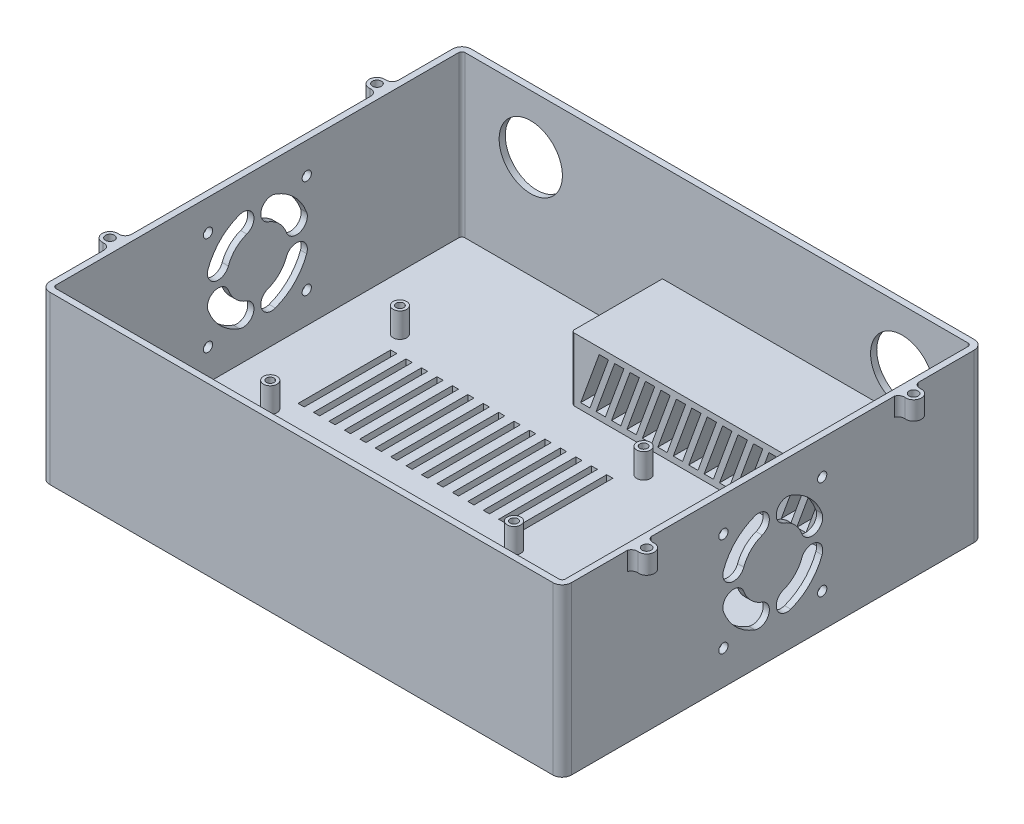
from build123d import *

# Parameters (mm, degrees)
EXTRUDE_4_DEPTH      = 52
EXTRUDE_5_DEPTH      = 2
EXTRUDE_6_DEPTH      = 20.5
SKETCH_14_R          = 10.25
CUT_EXTRUDE_2_DEPTH  = 2
CUT_EXTRUDE_4_DEPTH  = 35
CUT_EXTRUDE_5_DEPTH  = 0.05
SKETCH_25_R          = 10.15
CUT_EXTRUDE_6_DEPTH  = 2
SKETCH_26_R          = 2.2
SKETCH_26_R_2        = 1.25
EXTRUDE_13_DEPTH     = 8
SKETCH_30_W          = 2
SKETCH_30_H          = 30
CUT_EXTRUDE_8_DEPTH  = 8
SKETCH_31_R          = 1.5
CUT_EXTRUDE_11_DEPTH = 8
SKETCH_35_R          = 1.5
CUT_EXTRUDE_12_DEPTH = 8
SKETCH_37_R          = 1.45
EXTRUDE_14_DEPTH     = 6


with BuildPart() as part:
    # 草图2 → 凸台-拉伸4 (new body)
    with BuildSketch(Plane(origin=(0, 0, 0), x_dir=(1, 0, 0), z_dir=(0, 1, 0))):
        with BuildLine():
            Line((-81.5, -68.25), (81.5, -68.25))
            ThreePointArc((81.5, -68.25), (83.621320344, -67.371320344), (84.5, -65.25))
            Line((84.5, -65.25), (84.5, 65.25))
            ThreePointArc((84.5, 65.25), (83.621320344, 67.371320344), (81.5, 68.25))
            Line((81.5, 68.25), (-81.5, 68.25))
            ThreePointArc((-81.5, 68.25), (-83.621320344, 67.371320344), (-84.5, 65.25))
            Line((-84.5, 65.25), (-84.5, -65.25))
            ThreePointArc((-84.5, -65.25), (-83.621320344, -67.371320344), (-81.5, -68.25))
        make_face()
        with BuildLine():
            Line((-81.5, -66.25), (81.5, -66.25))
            ThreePointArc((81.5, -66.25), (82.207106781, -65.957106781), (82.5, -65.25))
            Line((82.5, -65.25), (82.5, 65.25))
            ThreePointArc((82.5, 65.25), (82.207106781, 65.957106781), (81.5, 66.25))
            Line((81.5, 66.25), (-81.5, 66.25))
            ThreePointArc((-81.5, 66.25), (-82.207106781, 65.957106781), (-82.5, 65.25))
            Line((-82.5, 65.25), (-82.5, -65.25))
            ThreePointArc((-82.5, -65.25), (-82.207106781, -65.957106781), (-81.5, -66.25))
        make_face(mode=Mode.SUBTRACT)
    extrude(amount=EXTRUDE_4_DEPTH)

    # 草图6 → 凸台-拉伸5 (add)
    with BuildSketch(Plane(origin=(0, 0, 0), x_dir=(-1, 0, 0), z_dir=(0, -1, 0))):
        with BuildLine():
            Line((81.5, -68.25), (-81.5, -68.25))
            ThreePointArc((-81.5, -68.25), (-83.621320344, -67.371320344), (-84.5, -65.25))
            Line((-84.5, -65.25), (-84.5, 65.25))
            ThreePointArc((-84.5, 65.25), (-83.621320344, 67.371320344), (-81.5, 68.25))
            Line((-81.5, 68.25), (81.5, 68.25))
            ThreePointArc((81.5, 68.25), (83.621320344, 67.371320344), (84.5, 65.25))
            Line((84.5, 65.25), (84.5, -65.25))
            ThreePointArc((84.5, -65.25), (83.621320344, -67.371320344), (81.5, -68.25))
        make_face()
    extrude(amount=EXTRUDE_5_DEPTH)

    # 草图7 → 凸台-拉伸6 (add)
    with BuildSketch(Plane(origin=(0, 0, 0), x_dir=(1, 0, 0), z_dir=(0, 1, 0))):
        with BuildLine():
            Line((-17.5, 66.25), (82.5, 66.25))
            Line((82.5, 66.25), (82.5, 36.75))
            Line((82.5, 36.75), (-16.5, 36.75))
            ThreePointArc((-16.5, 36.75), (-17.207106781, 37.042893219), (-17.5, 37.75))
            Line((-17.5, 37.75), (-17.5, 66.25))
        make_face()
    extrude(amount=EXTRUDE_6_DEPTH)

    # 草图14 → 切除-拉伸2 (cut)
    with BuildSketch(Plane(origin=(0, 0, -68.25), x_dir=(-1, 0, 0), z_dir=(0, 0, -1))):
        with Locations((-60.175, 33.275)):
            Circle(SKETCH_14_R)
        with Locations((60.175, 33.275)):
            Circle(SKETCH_14_R)
    extrude(amount=-CUT_EXTRUDE_2_DEPTH, mode=Mode.SUBTRACT)

    # 草图20 → 切除-拉伸4 (cut)
    with BuildSketch(Plane.XY.offset(-36.75)):
        Polygon((-14.5, 2), (-8.494491135, 18.5), (-5.494491135, 18.5), (-11.5, 2), align=None)
        Polygon((-9.5, 2), (-3.494491135, 18.5), (-0.494491135, 18.5), (-6.5, 2), align=None)
        Polygon((-4.5, 2), (1.505508865, 18.5), (4.505508865, 18.5), (-1.5, 2), align=None)
        Polygon((0.5, 2), (6.505508865, 18.5), (9.505508865, 18.5), (3.5, 2), align=None)
        Polygon((5.5, 2), (11.505508865, 18.5), (14.505508865, 18.5), (8.5, 2), align=None)
        Polygon((10.5, 2), (16.505508865, 18.5), (19.505508865, 18.5), (13.5, 2), align=None)
        Polygon((15.5, 2), (21.505508865, 18.5), (24.505508865, 18.5), (18.5, 2), align=None)
        Polygon((20.5, 2), (26.505508865, 18.5), (29.505508865, 18.5), (23.5, 2), align=None)
        Polygon((25.5, 2), (31.505508865, 18.5), (34.505508865, 18.5), (28.5, 2), align=None)
        Polygon((30.5, 2), (36.505508865, 18.5), (39.505508865, 18.5), (33.5, 2), align=None)
        Polygon((35.5, 2), (41.505508865, 18.5), (44.505508865, 18.5), (38.5, 2), align=None)
        Polygon((40.5, 2), (46.505508865, 18.5), (49.505508865, 18.5), (43.5, 2), align=None)
        Polygon((45.5, 2), (51.505508865, 18.5), (54.505508865, 18.5), (48.5, 2), align=None)
        Polygon((50.5, 2), (56.505508865, 18.5), (59.505508865, 18.5), (53.5, 2), align=None)
        Polygon((55.5, 2), (61.505508865, 18.5), (64.505508865, 18.5), (58.5, 2), align=None)
        Polygon((60.5, 2), (66.505508865, 18.5), (69.505508865, 18.5), (63.5, 2), align=None)
        Polygon((65.5, 2), (71.505508865, 18.5), (74.505508865, 18.5), (68.5, 2), align=None)
        Polygon((70.5, 2), (76.505508865, 18.5), (79.505508865, 18.5), (73.5, 2), align=None)
    extrude(amount=-CUT_EXTRUDE_4_DEPTH, mode=Mode.SUBTRACT)

    # 草图22 → 切除-拉伸5 (cut)
    with BuildSketch(Plane(origin=(0, 0, -68.25), x_dir=(-1, 0, 0), z_dir=(0, 0, -1))):
        with BuildLine():
            Line((31.2634375, 13.66), (27.5371875, 13.66))
            add(Edge.make_bspline(
                [(27.5371875, 13.66), (27.496962608, 13.835011517), (27.421006184, 14.165484724), (27.262554429, 14.622537656), (27.058671902, 15.00379895), (26.823863835, 15.319857525), (26.545806469, 15.562810535), (26.229939815, 15.740648132), (25.870213139, 15.840923537), (25.618524328, 15.853499856), (25.4884375, 15.86)],
                knots=[0, 0, 0, 0, 0.000538581, 0.001016999, 0.001446081, 0.001831096, 0.002191657, 0.002545569, 0.00291009, 0.003300046, 0.003300046, 0.003300046, 0.003300046], degree=3))
            add(Edge.make_bspline(
                [(25.4884375, 15.86), (25.383866285, 15.856190077), (25.179668881, 15.848750397), (24.883235573, 15.785994448), (24.60857001, 15.678031521), (24.354211787, 15.527249422), (24.118898633, 15.33649407), (23.903499541, 15.102777221), (23.71194781, 14.825103728), (23.539810148, 14.506718364), (23.390562451, 14.146389178), (23.254241995, 13.746594751), (23.149227013, 13.302550808), (23.053184478, 12.819324784), (22.98871941, 12.292893918), (22.936179888, 11.725567756), (22.90555333, 11.116582917), (22.901890431, 10.696907844), (22.9, 10.4803125)],
                knots=[0, 0, 0, 0, 0.000313492, 0.000612159, 0.000903881, 0.001195116, 0.001495755, 0.001809548, 0.002145229, 0.002505166, 0.002893345, 0.003314028, 0.003770906, 0.004261024, 0.004791436, 0.005360962, 0.005970185, 0.006619955, 0.006619955, 0.006619955, 0.006619955], degree=3))
            add(Edge.make_bspline(
                [(22.9, 10.4803125), (22.902185948, 10.247683479), (22.906419447, 9.797153737), (22.932913963, 9.145867531), (22.98011831, 8.541414907), (23.049105701, 7.98536753), (23.132497005, 7.475253762), (23.23947512, 7.014090437), (23.360861427, 6.599291438), (23.505464064, 6.232077204), (23.670046106, 5.907957491), (23.859150437, 5.629155807), (24.06729842, 5.390029002), (24.299174274, 5.194101438), (24.556540822, 5.046345225), (24.833014167, 4.937671858), (25.131153299, 4.870255117), (25.337974868, 4.863470082), (25.44375, 4.86)],
                knots=[0, 0, 0, 0, 0.000697889, 0.001351592, 0.001955077, 0.00251618, 0.003032137, 0.003504927, 0.00393559, 0.004327525, 0.004687282, 0.005023841, 0.005335576, 0.005635742, 0.005929945, 0.006221667, 0.006524421, 0.006841343, 0.006841343, 0.006841343, 0.006841343], degree=3))
            add(Edge.make_bspline(
                [(25.44375, 4.86), (25.528687053, 4.862564739), (25.693893769, 4.867553281), (25.934958076, 4.908673122), (26.158786664, 4.983166976), (26.372488067, 5.078095757), (26.567399238, 5.208347989), (26.753306745, 5.359117741), (26.917588837, 5.544827942), (27.069351835, 5.75568342), (27.206419006, 5.992877228), (27.326644736, 6.256999419), (27.433017069, 6.546694947), (27.524433558, 6.862838893), (27.604792756, 7.204396985), (27.66435339, 7.573331342), (27.713994403, 7.967632142), (27.731175596, 8.24007241), (27.74, 8.38)],
                knots=[0, 0, 0, 0, 0.000254746, 0.000495494, 0.000730303, 0.000961026, 0.001194624, 0.001431413, 0.001677212, 0.001935757, 0.002209918, 0.00249754, 0.002805326, 0.003134914, 0.00348429, 0.00385727, 0.004255501, 0.004676016, 0.004676016, 0.004676016, 0.004676016], degree=3))
            Line((27.74, 8.38), (25.4196875, 8.3903125))
            Line((25.4196875, 8.3903125), (25.4196875, 11.02))
            Line((25.4196875, 11.02), (31.48, 11.02))
            Line((31.48, 11.02), (31.48, 2))
            Line((31.48, 2), (29.795625, 2))
            Line((29.795625, 2), (29.4003125, 3.670625))
            add(Edge.make_bspline(
                [(29.4003125, 3.670625), (29.26487517, 3.518492854), (28.999731901, 3.220666439), (28.555005306, 2.83586519), (28.093941014, 2.505930703), (27.608025255, 2.236868526), (27.093045652, 2.034179505), (26.550836946, 1.884381642), (25.975834409, 1.798764676), (25.582672477, 1.786343699), (25.381875, 1.78)],
                knots=[0, 0, 0, 0, 0.000610493, 0.001195151, 0.001759791, 0.002309028, 0.002856713, 0.003416276, 0.003993336, 0.004595694, 0.004595694, 0.004595694, 0.004595694], degree=3))
            add(Edge.make_bspline(
                [(25.381875, 1.78), (25.164840843, 1.787283395), (24.738221211, 1.801600216), (24.114128669, 1.914212708), (23.522398963, 2.099790924), (22.962644358, 2.362942266), (22.430094063, 2.692712099), (21.932067871, 3.104106069), (21.467528288, 3.589206515), (21.035914601, 4.142139484), (20.647235175, 4.75528871), (20.30447631, 5.418133886), (20.019731586, 6.130309131), (19.787971612, 6.888743117), (19.600505874, 7.692168305), (19.472044452, 8.542684359), (19.396619086, 9.439667584), (19.385629981, 10.052768682), (19.38, 10.366875)],
                knots=[0, 0, 0, 0, 0.000650787, 0.001279239, 0.001895664, 0.002506205, 0.003130014, 0.00376998, 0.004438528, 0.005141301, 0.005870805, 0.006613376, 0.007376819, 0.00816837, 0.008990536, 0.009849588, 0.010746532, 0.011688808, 0.011688808, 0.011688808, 0.011688808], degree=3))
            add(Edge.make_bspline(
                [(19.38, 10.366875), (19.385431688, 10.688999699), (19.39602221, 11.317067631), (19.473873157, 12.233953087), (19.611842425, 13.098564382), (19.799631554, 13.91121919), (20.038376599, 14.673186461), (20.339553818, 15.379559664), (20.689713444, 16.037406359), (21.095225972, 16.637787707), (21.543871715, 17.179698854), (22.038083603, 17.651669199), (22.575217085, 18.048726811), (23.14804686, 18.379168578), (23.763411254, 18.631927924), (24.417277608, 18.80815386), (25.109678774, 18.923545478), (25.58535465, 18.934430379), (25.82875, 18.94)],
                knots=[0, 0, 0, 0, 0.000966329, 0.001884116, 0.002757816, 0.003590805, 0.004384413, 0.005149935, 0.005891224, 0.006616765, 0.007319647, 0.00799802, 0.008661467, 0.009318929, 0.009977082, 0.010650911, 0.011347155, 0.012076715, 0.012076715, 0.012076715, 0.012076715], degree=3))
            add(Edge.make_bspline(
                [(25.82875, 18.94), (26.012270844, 18.936402955), (26.372507275, 18.929342248), (26.899750301, 18.863153512), (27.40081752, 18.751980613), (27.879371109, 18.602785024), (28.32852279, 18.400547582), (28.757338009, 18.163529703), (29.155620397, 17.876381138), (29.527076584, 17.548043066), (29.872786478, 17.185205851), (30.177333078, 16.780171819), (30.450747433, 16.344800195), (30.689832215, 15.875021945), (30.886538744, 15.368353195), (31.052957042, 14.830075331), (31.180115255, 14.257304211), (31.23524192, 13.86212296), (31.2634375, 13.66)],
                knots=[0, 0, 0, 0, 0.000550387, 0.001080364, 0.001590795, 0.002088699, 0.002581174, 0.003065971, 0.003556282, 0.004050721, 0.004551653, 0.005056977, 0.005568195, 0.006092422, 0.006635645, 0.007196706, 0.007781333, 0.008393411, 0.008393411, 0.008393411, 0.008393411], degree=3))
        make_face()
        Polygon((38.375625, 18.5), (41.69625, 18.5), (47.32, 2), (43.7175, 2), (42.5315625, 5.74), (37.3890625, 5.74), (36.2615625, 2), (32.8, 2), align=None)
        Polygon((40.0084375, 14.4059375), (38.306875, 8.6), (41.675625, 8.6), align=None, mode=Mode.SUBTRACT)
        Polygon((52.675625, 18.5), (55.99625, 18.5), (61.62, 2), (58.0175, 2), (56.8315625, 5.74), (51.6890625, 5.74), (50.5615625, 2), (47.1, 2), align=None)
        Polygon((54.3084375, 14.4059375), (52.606875, 8.6), (55.975625, 8.6), align=None, mode=Mode.SUBTRACT)
        with BuildLine():
            Line((74.38, 13.66), (71.08, 13.66))
            Line((71.08, 13.66), (71.08, 13.8490625))
            add(Edge.make_bspline(
                [(71.08, 13.8490625), (71.072365078, 13.990895658), (71.057539839, 14.266302569), (70.93320551, 14.658978566), (70.723557061, 15.00707895), (70.439648089, 15.309515818), (70.092877094, 15.557034989), (69.690543734, 15.734362389), (69.242062357, 15.843051067), (68.926473048, 15.854219338), (68.763125, 15.86)],
                knots=[0, 0, 0, 0, 0.00042482, 0.000824901, 0.001221065, 0.001634538, 0.002060912, 0.002490215, 0.002946276, 0.00343561, 0.00343561, 0.00343561, 0.00343561], degree=3))
            add(Edge.make_bspline(
                [(68.763125, 15.86), (68.598784198, 15.854818957), (68.283039405, 15.84486472), (67.833666623, 15.748172435), (67.434755073, 15.584581067), (67.088835237, 15.36358858), (66.812103506, 15.086313106), (66.60326087, 14.770457159), (66.483671432, 14.408344563), (66.468034668, 14.154703749), (66.46, 14.024375)],
                knots=[0, 0, 0, 0, 0.000492535, 0.000946298, 0.001370171, 0.001780157, 0.002169066, 0.002537119, 0.00290671, 0.003297332, 0.003297332, 0.003297332, 0.003297332], degree=3))
            add(Edge.make_bspline(
                [(66.46, 14.024375), (66.466097065, 13.892748487), (66.477766622, 13.640820223), (66.599256899, 13.288941232), (66.798730643, 12.990484647), (67.028606275, 12.784202815), (67.266547487, 12.644848315), (67.501503557, 12.541034494), (67.788538795, 12.434546149), (68.128749781, 12.330090229), (68.520407515, 12.22277498), (68.965320078, 12.12293368), (69.460459477, 12.013394142), (69.81016379, 11.950306808), (69.99375, 11.9171875)],
                knots=[0, 0, 0, 0, 0.000393695, 0.000753518, 0.001100552, 0.001460818, 0.001668921, 0.001925816, 0.002230379, 0.002586985, 0.002993091, 0.003448362, 0.003954702, 0.004514286, 0.004514286, 0.004514286, 0.004514286], degree=3))
            add(Edge.make_bspline(
                [(69.99375, 11.9171875), (70.221092258, 11.865253275), (70.65851235, 11.765328723), (71.2816918, 11.590517161), (71.846324771, 11.400100229), (72.357108228, 11.206000471), (72.805795887, 10.985324838), (73.203094506, 10.763463844), (73.540470904, 10.520692202), (73.825231063, 10.263026809), (74.06393336, 9.981118765), (74.266858721, 9.673545736), (74.439772949, 9.337103124), (74.581825675, 8.971067713), (74.68499545, 8.573598766), (74.766415111, 8.149093128), (74.808691734, 7.694493054), (74.816162546, 7.382051217), (74.82, 7.2215625)],
                knots=[0, 0, 0, 0, 0.000699538, 0.001345952, 0.00194056, 0.002486982, 0.002983567, 0.003439357, 0.003850551, 0.004227691, 0.004588612, 0.004955668, 0.005330797, 0.005721479, 0.006130903, 0.006561044, 0.007016989, 0.007498546, 0.007498546, 0.007498546, 0.007498546], degree=3))
            add(Edge.make_bspline(
                [(74.82, 7.2215625), (74.814367205, 7.015088798), (74.803375476, 6.612179953), (74.727990838, 6.024570554), (74.598469196, 5.470784073), (74.410452027, 4.953437488), (74.177632208, 4.46666118), (73.884558212, 4.017746706), (73.544531137, 3.599324251), (73.149593007, 3.221738284), (72.712959147, 2.880395582), (72.232753059, 2.583259995), (71.709723965, 2.3355355), (71.147003143, 2.134550551), (70.546530351, 1.970974021), (69.904447677, 1.859235018), (69.222785738, 1.794828793), (68.755244099, 1.785024688), (68.515625, 1.78)],
                knots=[0, 0, 0, 0, 0.000619361, 0.001208609, 0.001773908, 0.002321928, 0.002856942, 0.003388989, 0.003926406, 0.004470965, 0.005024498, 0.005586369, 0.006161419, 0.006757307, 0.007376868, 0.008026228, 0.00870998, 0.00942882, 0.00942882, 0.00942882, 0.00942882], degree=3))
            add(Edge.make_bspline(
                [(68.515625, 1.78), (68.295385118, 1.784058311), (67.864996089, 1.791988994), (67.237201904, 1.870275633), (66.644407282, 1.992190188), (66.085293518, 2.164477766), (65.561730834, 2.389031064), (65.069704667, 2.65979228), (64.617368798, 2.987843521), (64.197075003, 3.357576305), (63.820349168, 3.773643895), (63.486928964, 4.226607818), (63.204882363, 4.718889499), (62.966097376, 5.246747706), (62.778248026, 5.814169089), (62.634283086, 6.416596341), (62.536354001, 7.0559805), (62.512314202, 7.495076472), (62.5, 7.72)],
                knots=[0, 0, 0, 0, 0.000660438, 0.001290618, 0.001894679, 0.002474191, 0.003042461, 0.003601042, 0.00415529, 0.004715381, 0.005277504, 0.005835788, 0.006399455, 0.006976402, 0.00757101, 0.008189655, 0.008832835, 0.009508301, 0.009508301, 0.009508301, 0.009508301], degree=3))
            Line((62.5, 7.72), (65.8, 7.72))
            add(Edge.make_bspline(
                [(65.8, 7.72), (65.805032973, 7.615558248), (65.814920571, 7.410375751), (65.861011095, 7.110340962), (65.927416611, 6.825317956), (66.024177068, 6.557824163), (66.133237274, 6.302196261), (66.278495788, 6.06802242), (66.440187503, 5.84607549), (66.623757299, 5.640015228), (66.832049096, 5.459472201), (67.050585364, 5.295953284), (67.287644557, 5.160871928), (67.538206729, 5.051894714), (67.802652029, 4.96464472), (68.082268783, 4.90216864), (68.377357757, 4.869611996), (68.57857741, 4.863234378), (68.680625, 4.86)],
                knots=[0, 0, 0, 0, 0.000313492, 0.000615874, 0.000909353, 0.001189841, 0.001468364, 0.001741315, 0.002014267, 0.002291748, 0.002566941, 0.002839892, 0.003109358, 0.003383346, 0.003658368, 0.003943597, 0.004241214, 0.004547461, 0.004547461, 0.004547461, 0.004547461], degree=3))
            add(Edge.make_bspline(
                [(68.680625, 4.86), (68.888510783, 4.866940838), (69.285706028, 4.880202293), (69.847236499, 4.988092119), (70.340930963, 5.174695862), (70.694458126, 5.396505908), (70.938080025, 5.604355586), (71.092064043, 5.776913783), (71.224201091, 5.961478182), (71.336154067, 6.157100813), (71.417803689, 6.368565834), (71.476030326, 6.592361959), (71.516105676, 6.828253745), (71.5186886, 6.991080015), (71.52, 7.07375)],
                knots=[0, 0, 0, 0, 0.000623335, 0.001190971, 0.001706779, 0.002197957, 0.002434346, 0.00266558, 0.002889757, 0.00311446, 0.003339793, 0.003567422, 0.003807605, 0.004055319, 0.004055319, 0.004055319, 0.004055319], degree=3))
            add(Edge.make_bspline(
                [(71.52, 7.07375), (71.51722885, 7.134662568), (71.511675291, 7.256735164), (71.470579708, 7.436587609), (71.39480303, 7.607767039), (71.295123368, 7.773699379), (71.164818538, 7.932374813), (71.011104524, 8.087656174), (70.824558509, 8.232313982), (70.612149149, 8.372837851), (70.369566298, 8.5057978), (70.101729008, 8.636806879), (69.804446326, 8.76073065), (69.479118728, 8.875658796), (69.126305381, 8.986997456), (68.743725143, 9.088362931), (68.333755094, 9.188565552), (68.049473349, 9.24715463), (67.90375, 9.2771875)],
                knots=[0, 0, 0, 0, 0.000182706, 0.000366154, 0.000549408, 0.000742184, 0.000945113, 0.001163874, 0.001396332, 0.001651842, 0.001927293, 0.002225544, 0.002546026, 0.002892873, 0.003260348, 0.0036556, 0.004079975, 0.004526294, 0.004526294, 0.004526294, 0.004526294], degree=3))
            add(Edge.make_bspline(
                [(67.90375, 9.2771875), (67.832638433, 9.291760737), (67.699430472, 9.319059689), (67.513315481, 9.362184079), (67.352244514, 9.39473015), (67.254014033, 9.417905767), (67.209375, 9.4284375)],
                knots=[0, 0, 0, 0, 0.00021776, 0.000407913, 0.000573092, 0.000710678, 0.000710678, 0.000710678, 0.000710678], degree=3))
            add(Edge.make_bspline(
                [(67.209375, 9.4284375), (67.027848568, 9.470094214), (66.675234903, 9.551012052), (66.169512757, 9.699985849), (65.700639806, 9.86203426), (65.273884264, 10.049677233), (64.883338729, 10.248127232), (64.529981833, 10.463060269), (64.220593676, 10.702413156), (63.943545328, 10.954825356), (63.704437138, 11.231657323), (63.501543089, 11.534631443), (63.324101968, 11.857653845), (63.183254116, 12.208930214), (63.07409334, 12.584437603), (62.994421949, 12.984542195), (62.951197477, 13.409259496), (62.943794828, 13.700013154), (62.94, 13.8490625)],
                knots=[0, 0, 0, 0, 0.000558612, 0.0010851, 0.001580863, 0.002045778, 0.002482395, 0.002894508, 0.003284342, 0.003654093, 0.00401725, 0.004378596, 0.004746216, 0.005120919, 0.00551142, 0.005917932, 0.0063431, 0.006790305, 0.006790305, 0.006790305, 0.006790305], degree=3))
            add(Edge.make_bspline(
                [(62.94, 13.8490625), (62.944289507, 14.034961479), (62.952690594, 14.39904845), (63.02826329, 14.930355593), (63.141807623, 15.436298302), (63.313153955, 15.912101984), (63.526029347, 16.36273037), (63.789465872, 16.784511075), (64.100840906, 17.17865017), (64.458457142, 17.541010729), (64.852004966, 17.871001678), (65.280674643, 18.158174967), (65.740655107, 18.397748178), (66.227018381, 18.600479765), (66.74673817, 18.749644263), (67.294043798, 18.858363826), (67.870888837, 18.930806886), (68.26560722, 18.936889057), (68.4675, 18.94)],
                knots=[0, 0, 0, 0, 0.000557395, 0.001091669, 0.001606973, 0.002110364, 0.00260546, 0.003099552, 0.00359883, 0.004109296, 0.004624245, 0.00513717, 0.005653814, 0.006177905, 0.006715256, 0.007272778, 0.007850943, 0.008456294, 0.008456294, 0.008456294, 0.008456294], degree=3))
            add(Edge.make_bspline(
                [(68.4675, 18.94), (68.69685309, 18.936663177), (69.142798859, 18.930175179), (69.791628118, 18.862026982), (70.400642493, 18.759400738), (70.968312474, 18.606190768), (71.497717188, 18.414858477), (71.986583071, 18.178086772), (72.435314394, 17.897174725), (72.840704926, 17.573809381), (73.204856548, 17.212152571), (73.517841957, 16.809544346), (73.789961705, 16.375007788), (74.005244856, 15.900070483), (74.174991773, 15.390909483), (74.293374582, 14.84579357), (74.367299035, 14.264740228), (74.375687467, 13.865335731), (74.38, 13.66)],
                knots=[0, 0, 0, 0, 0.000687809, 0.001337351, 0.00195505, 0.002538737, 0.003098797, 0.003641497, 0.004165104, 0.0046837, 0.005194142, 0.005700949, 0.006210349, 0.006728694, 0.00726134, 0.007817631, 0.008399626, 0.009015408, 0.009015408, 0.009015408, 0.009015408], degree=3))
        make_face()
    extrude(amount=-CUT_EXTRUDE_5_DEPTH, mode=Mode.SUBTRACT)

    # 草图25 → 切除-拉伸6 (cut)
    with BuildSketch(Plane(origin=(0, 0, 0), x_dir=(1, 0, 0), z_dir=(0, 1, 0))):
        with Locations((-60.15, -50.45)):
            Circle(SKETCH_25_R)
        with Locations((60.15, -50.45)):
            Circle(SKETCH_25_R)
    extrude(amount=-CUT_EXTRUDE_6_DEPTH, mode=Mode.SUBTRACT)

    # 草图26 → 凸台-拉伸13 (add)
    with BuildSketch(Plane(origin=(0, 0, 0), x_dir=(1, 0, 0), z_dir=(0, 1, 0))):
        with Locations((13.9, 28.75)):
            Circle(SKETCH_26_R)
        with Locations((13.9, 28.75)):
            Circle(SKETCH_26_R_2, mode=Mode.SUBTRACT)
        with Locations((13.9, -13.25)):
            Circle(SKETCH_26_R)
        with Locations((13.9, -13.25)):
            Circle(SKETCH_26_R_2, mode=Mode.SUBTRACT)
        with Locations((-65.065, -13.25)):
            Circle(SKETCH_26_R)
        with Locations((-65.065, -13.25)):
            Circle(SKETCH_26_R_2, mode=Mode.SUBTRACT)
        with Locations((-65.065, 28.75)):
            Circle(SKETCH_26_R)
        with Locations((-65.065, 28.75)):
            Circle(SKETCH_26_R_2, mode=Mode.SUBTRACT)
    extrude(amount=EXTRUDE_13_DEPTH)

    # 草图30 → 切除-拉伸8 (cut)
    with BuildSketch(Plane(origin=(0, 0, 0), x_dir=(1, 0, 0), z_dir=(0, 1, 0))):
        with Locations((-61.065, 7.75)):
            Rectangle(SKETCH_30_W, SKETCH_30_H)
        with Locations((-56.065, 7.75)):
            Rectangle(SKETCH_30_W, SKETCH_30_H)
        with Locations((-51.065, 7.75)):
            Rectangle(SKETCH_30_W, SKETCH_30_H)
        with Locations((-46.065, 7.75)):
            Rectangle(SKETCH_30_W, SKETCH_30_H)
        with Locations((-41.065, 7.75)):
            Rectangle(SKETCH_30_W, SKETCH_30_H)
        with Locations((-36.065, 7.75)):
            Rectangle(SKETCH_30_W, SKETCH_30_H)
        with Locations((-31.065, 7.75)):
            Rectangle(SKETCH_30_W, SKETCH_30_H)
        with Locations((-26.065, 7.75)):
            Rectangle(SKETCH_30_W, SKETCH_30_H)
        with Locations((-21.065, 7.75)):
            Rectangle(SKETCH_30_W, SKETCH_30_H)
        with Locations((-16.065, 7.75)):
            Rectangle(SKETCH_30_W, SKETCH_30_H)
        with Locations((-11.065, 7.75)):
            Rectangle(SKETCH_30_W, SKETCH_30_H)
        with Locations((-6.065, 7.75)):
            Rectangle(SKETCH_30_W, SKETCH_30_H)
        with Locations((-1.065, 7.75)):
            Rectangle(SKETCH_30_W, SKETCH_30_H)
        with Locations((3.935, 7.75)):
            Rectangle(SKETCH_30_W, SKETCH_30_H)
        with Locations((8.935, 7.75)):
            Rectangle(SKETCH_30_W, SKETCH_30_H)
    extrude(amount=-CUT_EXTRUDE_8_DEPTH, mode=Mode.SUBTRACT)

    # 草图31 → 切除-拉伸11 (cut)
    with BuildSketch(Plane(origin=(84.5, 0, 0), x_dir=(0, 0, -1), z_dir=(1, 0, 0))):
        with Locations((-16, 41)):
            Circle(SKETCH_31_R)
        with Locations((16, 41)):
            Circle(SKETCH_31_R)
        with Locations((16, 9)):
            Circle(SKETCH_31_R)
        with Locations((-16, 9)):
            Circle(SKETCH_31_R)
        with BuildLine():
            ThreePointArc((-5.814342437, 40.974774553), (-12.02081528, 37.02081528), (-15.974774553, 30.814342437))
            ThreePointArc((-15.974774553, 30.814342437), (-13.882920882, 26.328347762), (-9.396926208, 28.420201433))
            ThreePointArc((-9.396926208, 28.420201433), (-7.071067812, 32.071067812), (-3.420201433, 34.396926208))
            ThreePointArc((-3.420201433, 34.396926208), (-1.328347762, 38.882920882), (-5.814342437, 40.974774553))
        make_face()
        with BuildLine():
            ThreePointArc((15.974774553, 30.814342437), (12.02081528, 37.02081528), (5.814342437, 40.974774553))
            ThreePointArc((5.814342437, 40.974774553), (1.328347762, 38.882920882), (3.420201433, 34.396926208))
            ThreePointArc((3.420201433, 34.396926208), (7.071067812, 32.071067812), (9.396926208, 28.420201433))
            ThreePointArc((9.396926208, 28.420201433), (13.882920882, 26.328347762), (15.974774553, 30.814342437))
        make_face()
        with BuildLine():
            ThreePointArc((5.814342437, 9.025225447), (12.02081528, 12.97918472), (15.974774553, 19.185657563))
            ThreePointArc((15.974774553, 19.185657563), (13.882920882, 23.671652238), (9.396926208, 21.579798567))
            ThreePointArc((9.396926208, 21.579798567), (7.071067812, 17.928932188), (3.420201433, 15.603073792))
            ThreePointArc((3.420201433, 15.603073792), (1.328347762, 11.117079118), (5.814342437, 9.025225447))
        make_face()
        with BuildLine():
            ThreePointArc((-15.974774553, 19.185657563), (-12.02081528, 12.97918472), (-5.814342437, 9.025225447))
            ThreePointArc((-5.814342437, 9.025225447), (-1.328347762, 11.117079118), (-3.420201433, 15.603073792))
            ThreePointArc((-3.420201433, 15.603073792), (-7.071067812, 17.928932188), (-9.396926208, 21.579798567))
            ThreePointArc((-9.396926208, 21.579798567), (-13.882920882, 23.671652238), (-15.974774553, 19.185657563))
        make_face()
    extrude(amount=-CUT_EXTRUDE_11_DEPTH, mode=Mode.SUBTRACT)

    # 草图35 → 切除-拉伸12 (cut)
    with BuildSketch(Plane.ZY.offset(84.5)):
        with Locations((-16, 42)):
            Circle(SKETCH_35_R)
        with Locations((16, 42)):
            Circle(SKETCH_35_R)
        with Locations((16, 10)):
            Circle(SKETCH_35_R)
        with Locations((-16, 10)):
            Circle(SKETCH_35_R)
        with BuildLine():
            ThreePointArc((-5.814342437, 41.974774553), (-12.02081528, 38.02081528), (-15.974774553, 31.814342437))
            ThreePointArc((-15.974774553, 31.814342437), (-13.882920882, 27.328347762), (-9.396926208, 29.420201433))
            ThreePointArc((-9.396926208, 29.420201433), (-7.071067812, 33.071067812), (-3.420201433, 35.396926208))
            ThreePointArc((-3.420201433, 35.396926208), (-1.328347762, 39.882920882), (-5.814342437, 41.974774553))
        make_face()
        with BuildLine():
            ThreePointArc((15.974774553, 31.814342437), (12.02081528, 38.02081528), (5.814342437, 41.974774553))
            ThreePointArc((5.814342437, 41.974774553), (1.328347762, 39.882920882), (3.420201433, 35.396926208))
            ThreePointArc((3.420201433, 35.396926208), (7.071067812, 33.071067812), (9.396926208, 29.420201433))
            ThreePointArc((9.396926208, 29.420201433), (13.882920882, 27.328347762), (15.974774553, 31.814342437))
        make_face()
        with BuildLine():
            ThreePointArc((5.814342437, 10.025225447), (12.02081528, 13.97918472), (15.974774553, 20.185657563))
            ThreePointArc((15.974774553, 20.185657563), (13.882920882, 24.671652238), (9.396926208, 22.579798567))
            ThreePointArc((9.396926208, 22.579798567), (7.071067812, 18.928932188), (3.420201433, 16.603073792))
            ThreePointArc((3.420201433, 16.603073792), (1.328347762, 12.117079118), (5.814342437, 10.025225447))
        make_face()
        with BuildLine():
            ThreePointArc((-15.974774553, 20.185657563), (-12.02081528, 13.97918472), (-5.814342437, 10.025225447))
            ThreePointArc((-5.814342437, 10.025225447), (-1.328347762, 12.117079118), (-3.420201433, 16.603073792))
            ThreePointArc((-3.420201433, 16.603073792), (-7.071067812, 18.928932188), (-9.396926208, 22.579798567))
            ThreePointArc((-9.396926208, 22.579798567), (-13.882920882, 24.671652238), (-15.974774553, 20.185657563))
        make_face()
    extrude(amount=-CUT_EXTRUDE_12_DEPTH, mode=Mode.SUBTRACT)

    # 草图37 → 凸台-拉伸14 (add)
    with BuildSketch(Plane(origin=(0, 52, 0), x_dir=(1, 0, 0), z_dir=(0, 1, 0))):
        with BuildLine():
            Line((-84.5, 47.722135955), (-84.5, 38.777864045))
            ThreePointArc((-84.5, 38.777864045), (-85.166666667, 40.26857603), (-86.722222222, 40.765480025))
            ThreePointArc((-86.722222222, 40.765480025), (-89.5, 43.25), (-86.722222222, 45.734519975))
            ThreePointArc((-86.722222222, 45.734519975), (-85.166666667, 46.23142397), (-84.5, 47.722135955))
        make_face()
        with Locations((-87, 43.25)):
            Circle(SKETCH_37_R, mode=Mode.SUBTRACT)
        with BuildLine():
            Line((84.37, 47.722135955), (84.37, 38.777864045))
            ThreePointArc((84.37, 38.777864045), (85.036666667, 40.26857603), (86.592222222, 40.765480025))
            ThreePointArc((86.592222222, 40.765480025), (89.37, 43.25), (86.592222222, 45.734519975))
            ThreePointArc((86.592222222, 45.734519975), (85.036666667, 46.23142397), (84.37, 47.722135955))
        make_face()
        with Locations((86.87, 43.25)):
            Circle(SKETCH_37_R, mode=Mode.SUBTRACT)
        with BuildLine():
            Line((84.37, -47.722135955), (84.37, -38.777864045))
            ThreePointArc((84.37, -38.777864045), (85.036666667, -40.26857603), (86.592222222, -40.765480025))
            ThreePointArc((86.592222222, -40.765480025), (89.37, -43.25), (86.592222222, -45.734519975))
            ThreePointArc((86.592222222, -45.734519975), (85.036666667, -46.23142397), (84.37, -47.722135955))
        make_face()
        with Locations((86.87, -43.25)):
            Circle(SKETCH_37_R, mode=Mode.SUBTRACT)
        with BuildLine():
            Line((-84.5, -47.722135955), (-84.5, -38.777864045))
            ThreePointArc((-84.5, -38.777864045), (-85.166666667, -40.26857603), (-86.722222222, -40.765480025))
            ThreePointArc((-86.722222222, -40.765480025), (-89.5, -43.25), (-86.722222222, -45.734519975))
            ThreePointArc((-86.722222222, -45.734519975), (-85.166666667, -46.23142397), (-84.5, -47.722135955))
        make_face()
        with Locations((-87, -43.25)):
            Circle(SKETCH_37_R, mode=Mode.SUBTRACT)
    extrude(amount=-EXTRUDE_14_DEPTH)


solid = part.part
